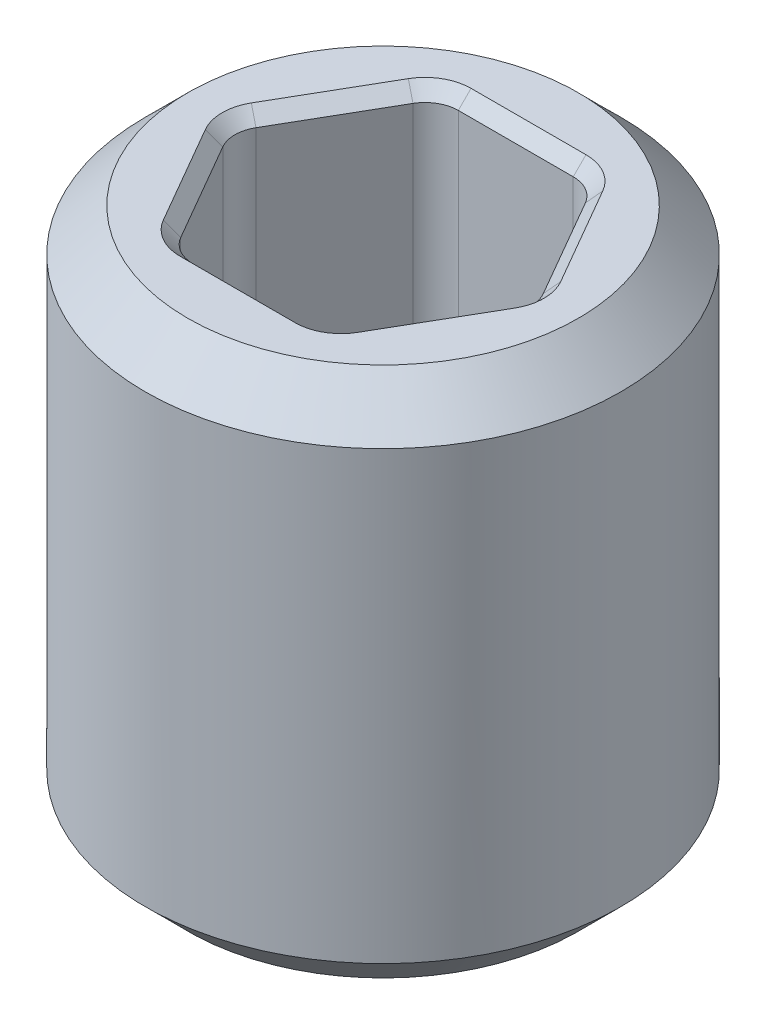
from build123d import *

# Parameters (mm, degrees)
SKETCH1_W               = 1.4224
SKETCH1_H               = 3.175
CUT_EXTRUDE1_DEPTH      = 2.5875
CUT_EXTRUDE1_DEPTH_BACK = 2.5875
FILLET1_R               = 0.1984375
CHAMFER1_SIZE           = 0.254
CHAMFER2_SIZE           = 0.0762


with BuildPart() as part:
    # Sketch1 → Revolve1 (revolve)
    with BuildSketch(Plane.XY):
        with Locations((0.7112, 0)):
            Rectangle(SKETCH1_W, SKETCH1_H)
    revolve(axis=Axis((0, -1.704166029, 0), (0, 1, 0)))

    # Sketch3 → Cut-Extrude1 (cut, two sides)
    with BuildSketch(Plane(origin=(0, 0, 0), x_dir=(1, 0, 0), z_dir=(0, 1, 0))) as cut_extrude1_sk:
        Polygon((0.916543552, 0), (0.458271776, 0.79375), (-0.458271776, 0.79375), (-0.916543552, 0), (-0.458271776, -0.79375), (0.458271776, -0.79375), align=None)
    extrude(amount=CUT_EXTRUDE1_DEPTH, mode=Mode.SUBTRACT)
    extrude(cut_extrude1_sk.sketch, amount=-CUT_EXTRUDE1_DEPTH_BACK, mode=Mode.SUBTRACT)

    # Fillet1
    fillet1_edges = [part.edges().sort_by_distance(p)[0] for p in [
        (0.458271776, 0, -0.79375),
        (0.916543552, 0, 0),
        (0.458271776, 0, 0.79375),
        (-0.458271776, 0, 0.79375),
        (-0.916543552, 0, 0),
        (-0.458271776, 0, -0.79375),
    ]]
    fillet(fillet1_edges, radius=FILLET1_R)

    # Chamfer1
    chamfer1_edges = [part.edges().sort_by_distance(p)[0] for p in [
        (-1.4224, 1.5875, 0),
        (-1.4224, -1.5875, 0),
    ]]
    chamfer(chamfer1_edges, length=CHAMFER1_SIZE)

    # Chamfer2
    chamfer2_edges = [part.edges().sort_by_distance(p)[0] for p in [
        (0.687407664, -1.5875, -0.396875),
        (0.687407664, 1.5875, -0.396875),
        (0.687407664, -1.5875, 0.396875),
        (0.687407664, 1.5875, 0.396875),
        (0, -1.5875, 0.79375),
        (0, 1.5875, 0.79375),
        (-0.687407664, -1.5875, 0.396875),
        (-0.687407664, 1.5875, 0.396875),
        (-0.687407664, -1.5875, -0.396875),
        (-0.687407664, 1.5875, -0.396875),
        (0, -1.5875, -0.79375),
        (0, 1.5875, -0.79375),
        (0.885845164, 1.5875, 0),
        (0.885845164, -1.5875, 0),
        (0.442922582, 1.5875, 0.767164416),
        (0.442922582, -1.5875, 0.767164416),
        (-0.442922582, 1.5875, 0.767164416),
        (-0.442922582, -1.5875, 0.767164416),
        (-0.885845164, 1.5875, 0),
        (-0.885845164, -1.5875, 0),
        (-0.442922582, 1.5875, -0.767164416),
        (-0.442922582, -1.5875, -0.767164416),
        (0.442922582, 1.5875, -0.767164416),
        (0.442922582, -1.5875, -0.767164416),
    ]]
    chamfer(chamfer2_edges, length=CHAMFER2_SIZE)


solid = part.part
